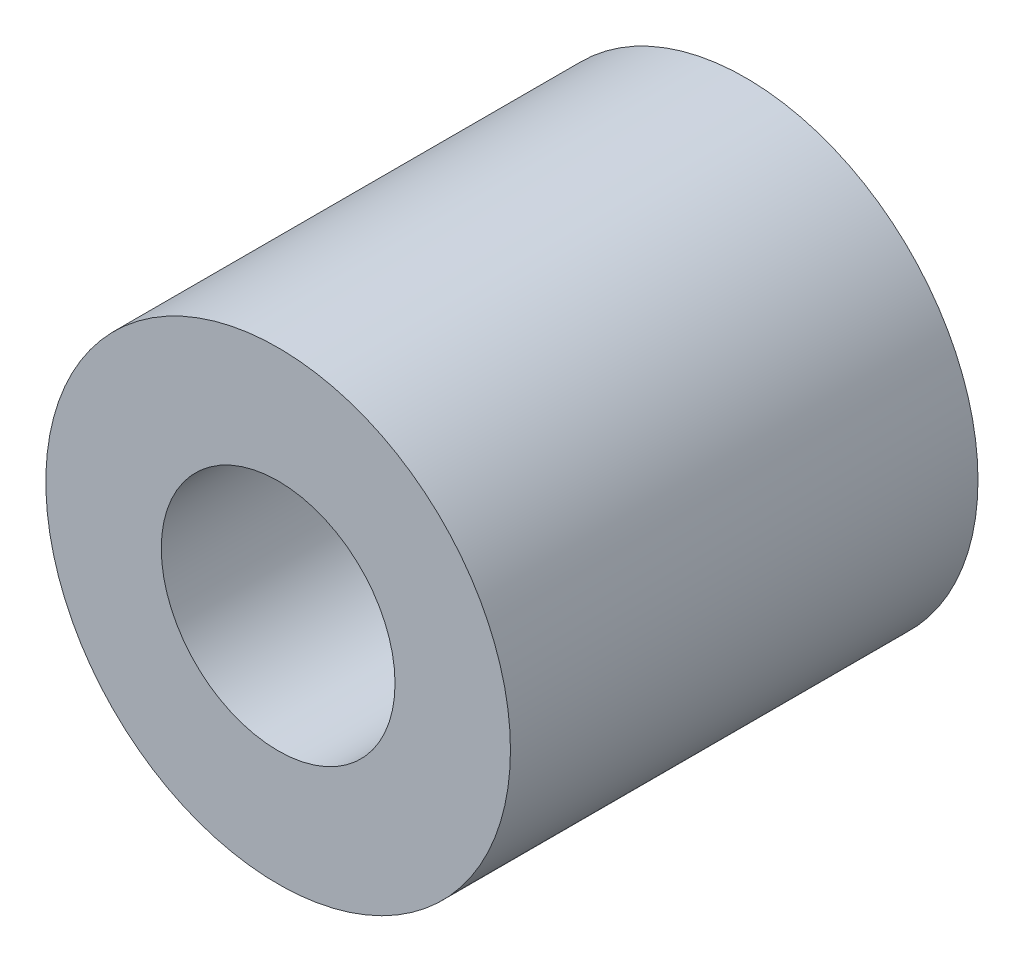
from build123d import *

# Parameters (mm, degrees)
SKETCH1_R           = 7.95
SKETCH1_R_2         = 4
BOSS_EXTRUDE1_DEPTH = 16


with BuildPart() as part:
    # Sketch1 → Boss-Extrude1 (new body)
    with BuildSketch(Plane.XY):
        Circle(SKETCH1_R)
        Circle(SKETCH1_R_2, mode=Mode.SUBTRACT)
    extrude(amount=BOSS_EXTRUDE1_DEPTH)


solid = part.part
